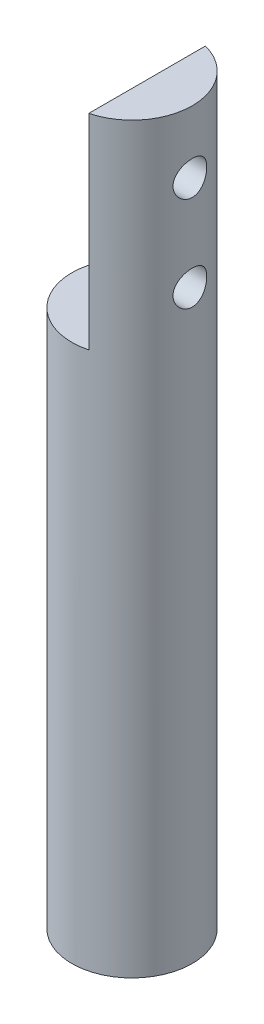
from build123d import *

# Parameters (mm, degrees)
SKETCH_1_R          = 3.175
EXTRUDE_1_DEPTH     = 57.15
CUT_EXTRUDE_1_DEPTH = 10.795
SKETCH_3_R          = 0.889
CUT_EXTRUDE_2_DEPTH = 10.795
SKETCH_4_W          = 3.926157487
SKETCH_4_H          = 0.79375
CUT_EXTRUDE_3_DEPTH = 8.573
SKETCH_5_R          = 3.774888962
CUT_EXTRUDE_4_DEPTH = 18


with BuildPart() as part:
    # 草图1 → 凸台-拉伸1 (new body)
    with BuildSketch(Plane(origin=(0, 0, 0), x_dir=(1, 0, 0), z_dir=(0, 1, 0))):
        Circle(SKETCH_1_R)
    extrude(amount=EXTRUDE_1_DEPTH)

    # 草图2 → 切除-拉伸1 (cut)
    with BuildSketch(Plane(origin=(0, 57.15, 0), x_dir=(1, 0, 0), z_dir=(0, 1, 0))):
        Polygon((-0.794, 3.175), (0.794, 3.175), (0.794, -3.175), (-3.175, -3.175), (-3.175, 3.175), align=None)
    extrude(amount=-CUT_EXTRUDE_1_DEPTH, mode=Mode.SUBTRACT)

    # 草图3 → 切除-拉伸2 (cut)
    with BuildSketch(Plane.ZY.offset(-0.794)):
        with Locations((0, 53.855)):
            Circle(SKETCH_3_R)
        with Locations((0, 48.855)):
            Circle(SKETCH_3_R)
    extrude(amount=-CUT_EXTRUDE_2_DEPTH, mode=Mode.SUBTRACT)

    # 草图4 → 切除-拉伸3 (cut)
    with BuildSketch(Plane.XZ):
        with Locations((-0.018009896, -2.778125)):
            Rectangle(SKETCH_4_W, SKETCH_4_H)
    extrude(amount=-CUT_EXTRUDE_3_DEPTH, mode=Mode.SUBTRACT)

    # 草图5 → 切除-拉伸4 (cut)
    with BuildSketch(Plane.XZ):
        Circle(SKETCH_5_R)
    extrude(amount=-CUT_EXTRUDE_4_DEPTH, mode=Mode.SUBTRACT)


solid = part.part
